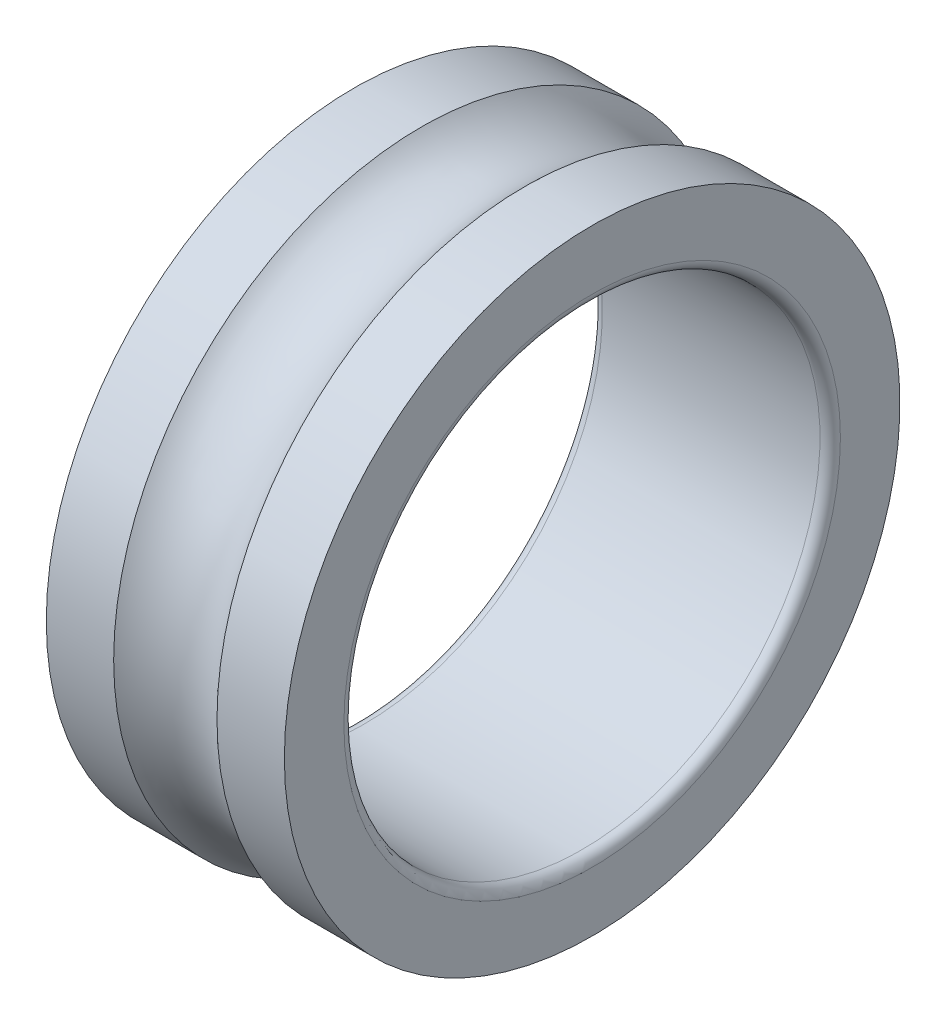
from build123d import *


with BuildPart() as part:
    # Sketch1 → Revolve1 (revolve)
    with BuildSketch(Plane.XY):
        with BuildLine():
            Line((0, 4.525), (0, 3.65))
            ThreePointArc((0, 3.65), (0.043933983, 3.543933983), (0.15, 3.5))
            Line((0.15, 3.5), (3.35, 3.5))
            ThreePointArc((3.35, 3.5), (3.456066017, 3.543933983), (3.5, 3.65))
            Line((3.5, 3.65), (3.5, 4.525))
            Line((3.5, 4.525), (2.509522877, 4.525))
            ThreePointArc((2.509522877, 4.525), (1.75, 4.2), (0.990477123, 4.525))
            Line((0.990477123, 4.525), (0, 4.525))
        make_face()
    revolve(axis=Axis((3.5, 0, 0), (-1, 0, 0)))


solid = part.part
